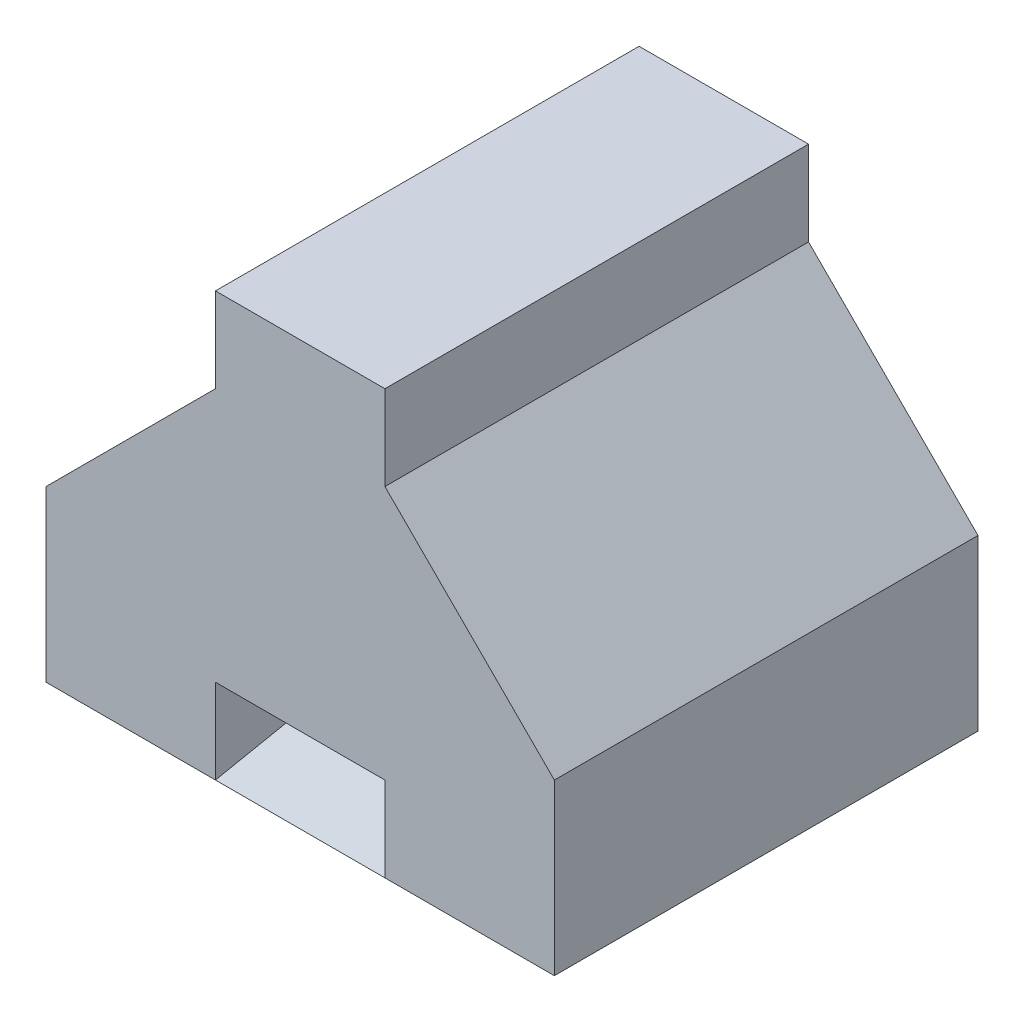
from build123d import *

# Parameters (mm, degrees)
BOSS_EXTRUDE1_DEPTH = 25
SKETCH2_W           = 10
SKETCH2_H           = 5
CUT_EXTRUDE1_DEPTH  = 46
BOSS_EXTRUDE3_DEPTH = 10


with BuildPart() as part:
    # Sketch1 → Boss-Extrude1 (new body)
    with BuildSketch(Plane.XY):
        Polygon((-30, 0), (-30, 10), (-20, 20), (-20, 25), (-10, 25), (-10, 20), (0, 10), (0, 0), align=None)
    extrude(amount=BOSS_EXTRUDE1_DEPTH)

    # Sketch2 → Cut-Extrude1 (cut)
    with BuildSketch(Plane.XY.offset(25)):
        with Locations((-15, 2.5)):
            Rectangle(SKETCH2_W, SKETCH2_H)
    extrude(amount=-CUT_EXTRUDE1_DEPTH, mode=Mode.SUBTRACT)


with BuildPart() as body_2:
    # Sketch3 → Boss-Extrude3 (new body)
    with BuildSketch(Plane(origin=(-20, 0, 0), x_dir=(0, 0, -1), z_dir=(1, 0, 0))):
        Polygon((-25, 0), (0, 5), (0, 0), align=None)
    extrude(amount=BOSS_EXTRUDE3_DEPTH)


solid = Compound([part.part, body_2.part])
